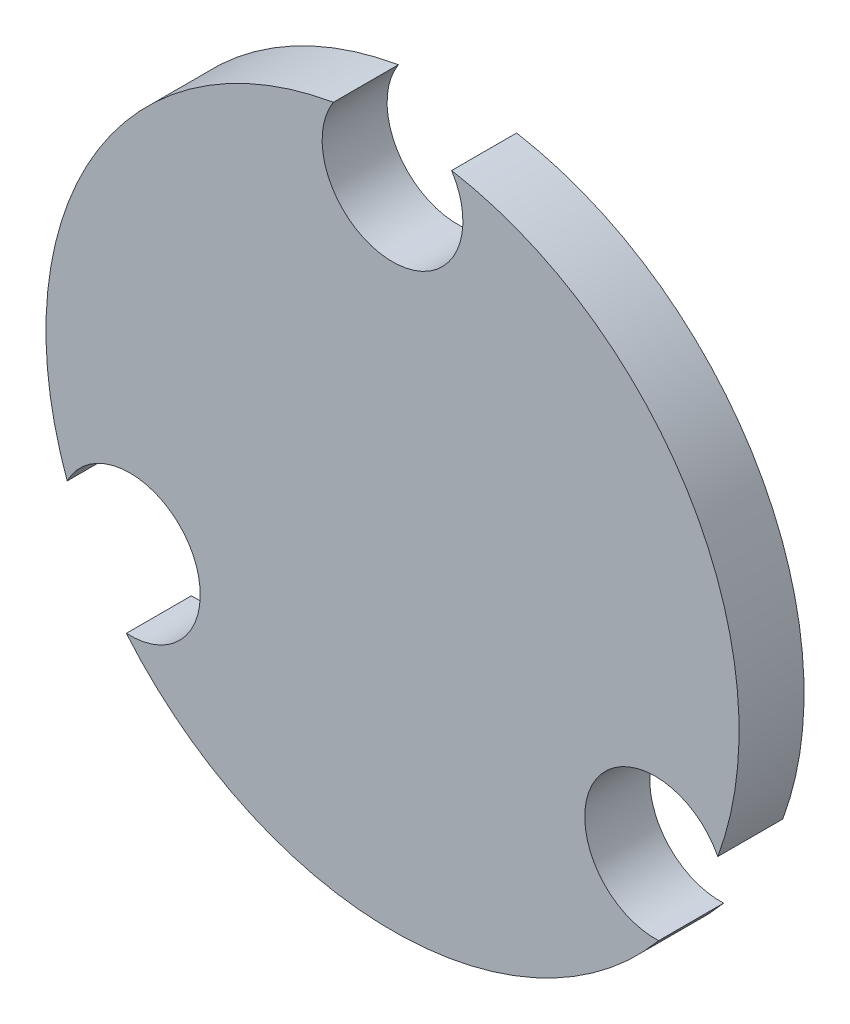
from build123d import *

# Parameters (mm, degrees)
BOSS_EXTRU_2_DEPTH = 3


with BuildPart() as part:
    # Esquisse1 → Boss.-Extru.2 (new body)
    with BuildSketch(Plane.XY):
        with BuildLine():
            ThreePointArc((-12.288149304, -10.247018429), (0.000780623, -15.999999981), (12.289149128, -10.245819328))
            ThreePointArc((12.289149128, -10.245819328), (9.309773091, -5.375), (15.017714385, -5.519805672))
            ThreePointArc((15.017714385, -5.519805672), (13.856406461, 8), (2.728565257, 15.765625))
            ThreePointArc((2.728565257, 15.765625), (0, 10.75), (-2.728565257, 15.765625))
            ThreePointArc((-2.728565257, 15.765625), (-13.856384318, 8.000038352), (-15.01774494, -5.519722539))
            ThreePointArc((-15.01774494, -5.519722539), (-9.310492225, -5.375986513), (-12.288149304, -10.247018429))
        make_face()
    extrude(amount=BOSS_EXTRU_2_DEPTH)


solid = part.part
